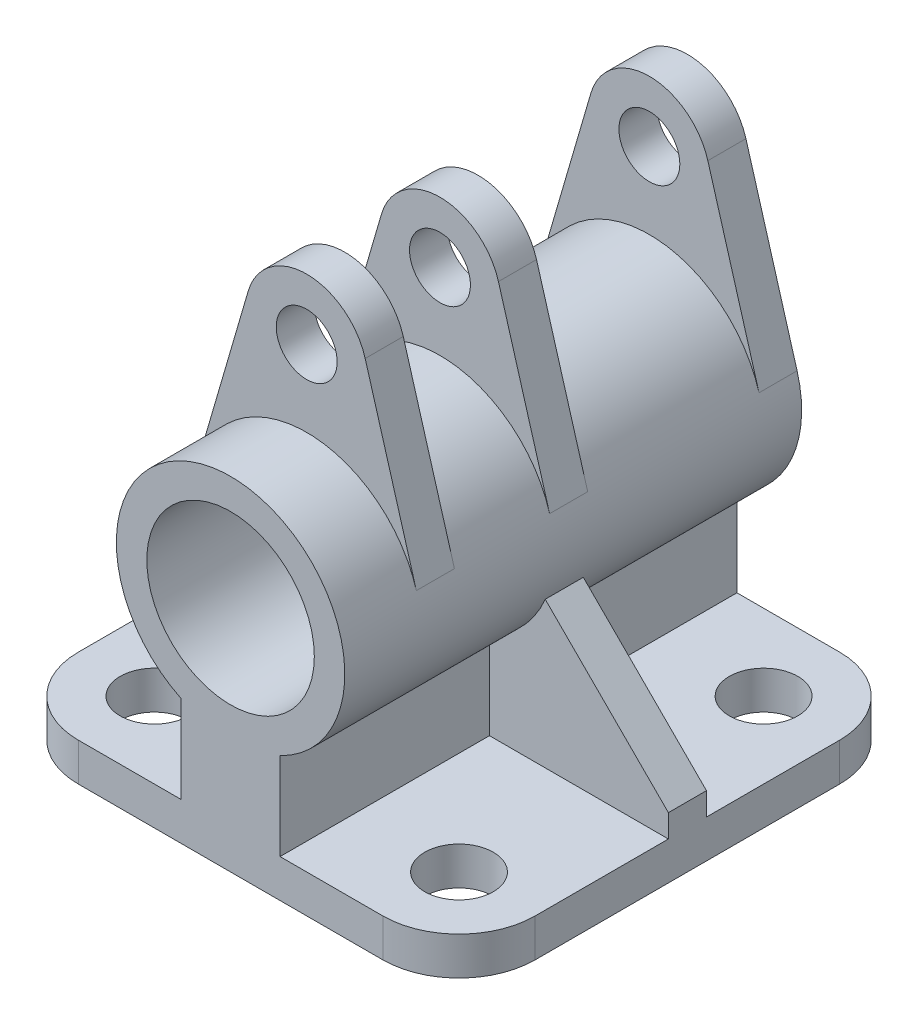
from build123d import *

# Parameters (mm, degrees)
SKETCH_2_R               = 11
EXTRUDE_2_DEPTH          = 30
SKETCH_2_6_R             = 4
EXTRUDE_3_DEPTH          = 2.5
EXTRUDE_START            = 15
EXTRUDE_4_DEPTH          = 5
EXTRUDE_START_2          = -30
EXTRUDE_5_DEPTH          = 5
SKETCH_4_R               = 4.5
CUT_EXTRUDE_1_DEPTH      = 72.860976893
MIRROR_2_COPY_1_SKETCH_R = 4.5
MIRROR_2_COPY_1_DEPTH    = 72.860976893
FILLET_1_R               = 10


with BuildPart() as part:
    # Эскиз2 → Бобышка-Вытянуть2 (new, symmetric)
    with BuildSketch(Plane.XY):
        with BuildLine():
            Line((-6.5, -13.518505835), (-6.5, -25))
            Line((-6.5, -25), (-30, -25))
            Line((-30, -25), (-30, -30))
            Line((-30, -30), (30, -30))
            Line((30, -30), (30, -25))
            Line((30, -25), (6.5, -25))
            Line((6.5, -25), (6.5, -13.518505835))
            ThreePointArc((6.5, -13.518505835), (0, 15), (-6.5, -13.518505835))
        make_face()
        Circle(SKETCH_2_R, mode=Mode.SUBTRACT)
    extrude(amount=EXTRUDE_2_DEPTH, both=True)

    # Эскиз2<6> → Бобышка-Вытянуть3 (add, symmetric)
    with BuildSketch(Plane.XY):
        with BuildLine():
            ThreePointArc((-14.4, 4.2), (-9, 12), (0, 15))
            ThreePointArc((0, 15), (9, 12), (14.4, 4.2))
            Line((14.4, 4.2), (7.68, 27.24))
            ThreePointArc((7.68, 27.24), (0, 33), (-7.68, 27.24))
            Line((-7.68, 27.24), (-14.4, 4.2))
        make_face()
        with Locations((0, 25)):
            Circle(SKETCH_2_6_R, mode=Mode.SUBTRACT)
        with BuildLine():
            ThreePointArc((-6.5, -13.518505835), (-10.865729218, -10.340982959), (-13.823441352, -5.823441352))
            Line((-13.823441352, -5.823441352), (-30, -22))
            Line((-30, -22), (-30, -25))
            Line((-30, -25), (-6.5, -25))
            Line((-6.5, -25), (-6.5, -13.518505835))
        make_face()
        with BuildLine():
            Line((30, -22), (13.823441352, -5.823441352))
            ThreePointArc((13.823441352, -5.823441352), (10.865729218, -10.340982959), (6.5, -13.518505835))
            Line((6.5, -13.518505835), (6.5, -25))
            Line((6.5, -25), (30, -25))
            Line((30, -25), (30, -22))
        make_face()
    extrude(amount=EXTRUDE_3_DEPTH, both=True)

    # Эскиз2<8> → Бобышка-Вытянуть4 (add)
    with BuildSketch(Plane.XY.offset(EXTRUDE_START)):
        with BuildLine():
            ThreePointArc((-14.4, 4.2), (-9, 12), (0, 15))
            ThreePointArc((0, 15), (9, 12), (14.4, 4.2))
            Line((14.4, 4.2), (7.68, 27.24))
            ThreePointArc((7.68, 27.24), (0, 33), (-7.68, 27.24))
            Line((-7.68, 27.24), (-14.4, 4.2))
        make_face()
        with BuildLine():
            ThreePointArc((4, 25), (2.828427125, 22.171572875), (0, 21))
            ThreePointArc((0, 21), (-2.828427125, 27.828427125), (4, 25))
        make_face(mode=Mode.SUBTRACT)
    extrude(amount=EXTRUDE_4_DEPTH)

    # Эскиз2<9> → Бобышка-Вытянуть5 (add)
    with BuildSketch(Plane.XY.offset(EXTRUDE_START_2)):
        with BuildLine():
            ThreePointArc((-14.4, 4.2), (-9, 12), (0, 15))
            ThreePointArc((0, 15), (9, 12), (14.4, 4.2))
            Line((14.4, 4.2), (7.68, 27.24))
            ThreePointArc((7.68, 27.24), (0, 33), (-7.68, 27.24))
            Line((-7.68, 27.24), (-14.4, 4.2))
        make_face()
        with BuildLine():
            ThreePointArc((4, 25), (2.828427125, 22.171572875), (0, 21))
            ThreePointArc((0, 21), (-2.828427125, 27.828427125), (4, 25))
        make_face(mode=Mode.SUBTRACT)
    extrude(amount=EXTRUDE_5_DEPTH)

    # Эскиз4 → Вырез-Вытянуть1 (cut, through all)
    with BuildSketch(Plane(origin=(0, -25, 0), x_dir=(1, 0, 0), z_dir=(0, 1, 0))):
        with Locations(Location((20, 20, 0), (0, 0, 270))):
            Circle(SKETCH_4_R)
    cut_extrude_1 = extrude(amount=-CUT_EXTRUDE_1_DEPTH, mode=Mode.SUBTRACT)

    # Зеркальное отражение1: Вырез-Вытянуть1 across plane
    add(cut_extrude_1.mirror(Plane.XY), mode=Mode.SUBTRACT)

    # Зеркальное отражение2: Вырез-Вытянуть1 across plane
    add(cut_extrude_1.mirror(Plane(origin=(0, 0, 0), x_dir=(0, 0, 1), z_dir=(1, 0, 0))), mode=Mode.SUBTRACT)

    # Зеркальное отражение2 copy 1 sketch → Зеркальное отражение2 copy 1 (cut, through all)
    with BuildSketch(Plane(origin=(0, -25, 0), x_dir=(-1, 0, 0), z_dir=(0, 1, 0))):
        with Locations(Location((20, 20, 0), (0, 0, 270))):
            Circle(MIRROR_2_COPY_1_SKETCH_R)
    extrude(amount=-MIRROR_2_COPY_1_DEPTH, mode=Mode.SUBTRACT)

    # Скругление1
    fillet_1_edges = [part.edges().sort_by_distance(p)[0] for p in [
        (30, -27.5, -30),
        (-30, -27.5, -30),
        (-30, -27.5, 30),
        (30, -27.5, 30),
    ]]
    fillet(fillet_1_edges, radius=FILLET_1_R)


solid = part.part
